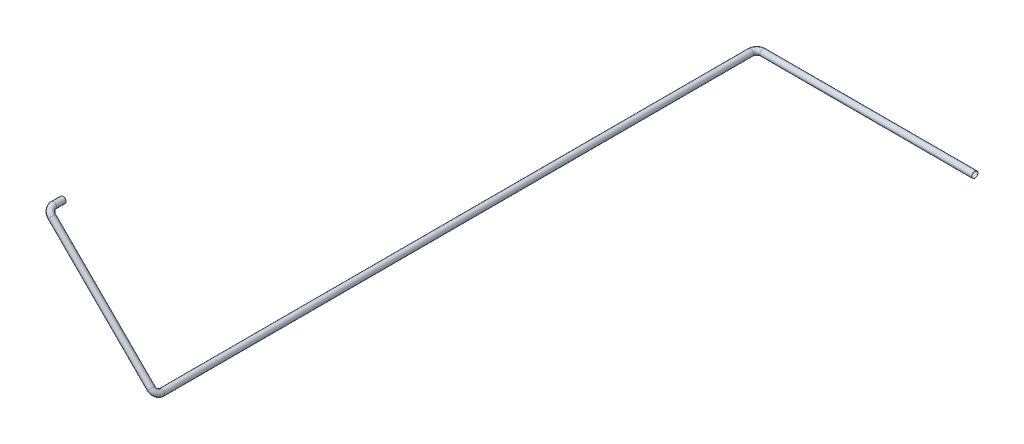
from build123d import *

# Parameters (mm, degrees)
SWEEP_THIN1_PROFILE_R   = 30
SWEEP_THIN1_PROFILE_R_2 = 29


with BuildPart() as part:
    # Sweep-Thin1: sweep along a curve in space
    with BuildLine() as sweep_thin1_path:
        Line((-38227.538989442, -15786.327639419, 44714.700196057), (-38227.538989442, -15786.327639419, 44805.879708995))
        ThreePointArc((-38185.112582571, -15828.75404629, 44865.879708995), (-38215.112582571, -15798.75404629, 44848.306115867), (-38227.538989442, -15786.327639419, 44805.879708995))
        Line((-37225.272207615, -16788.594421246, 44865.879708995), (-38185.112582571, -15828.75404629, 44865.879708995))
        ThreePointArc((-37182.845800744, -16831.020828117, 44805.879708995), (-37195.272207615, -16818.594421246, 44848.306115867), (-37225.272207615, -16788.594421246, 44865.879708995))
        Line((-37182.845800744, -16831.020828117, 44805.879708995), (-37182.845800744, -16831.020828117, 39111.700196057))
        ThreePointArc((-37122.845800744, -16831.020828117, 39051.700196057), (-37165.272207615, -16831.020828117, 39069.273789186), (-37182.845800744, -16831.020828117, 39111.700196057))
        Line((-37122.845800744, -16831.020828117, 39051.700196057), (-35073.51869548, -16831.020828117, 39051.700196057))
    # Sweep-Thin1 profile (on start of the path) → Sweep-Thin1 (sweep)
    with BuildSketch(Plane(origin=(-38227.538989442, -15786.327639419, 44714.700196057), x_dir=(1, 0, 0), z_dir=(0, 0, 1))):
        Circle(SWEEP_THIN1_PROFILE_R)
        Circle(SWEEP_THIN1_PROFILE_R_2, mode=Mode.SUBTRACT)
    sweep(path=sweep_thin1_path.line)


solid = part.part
